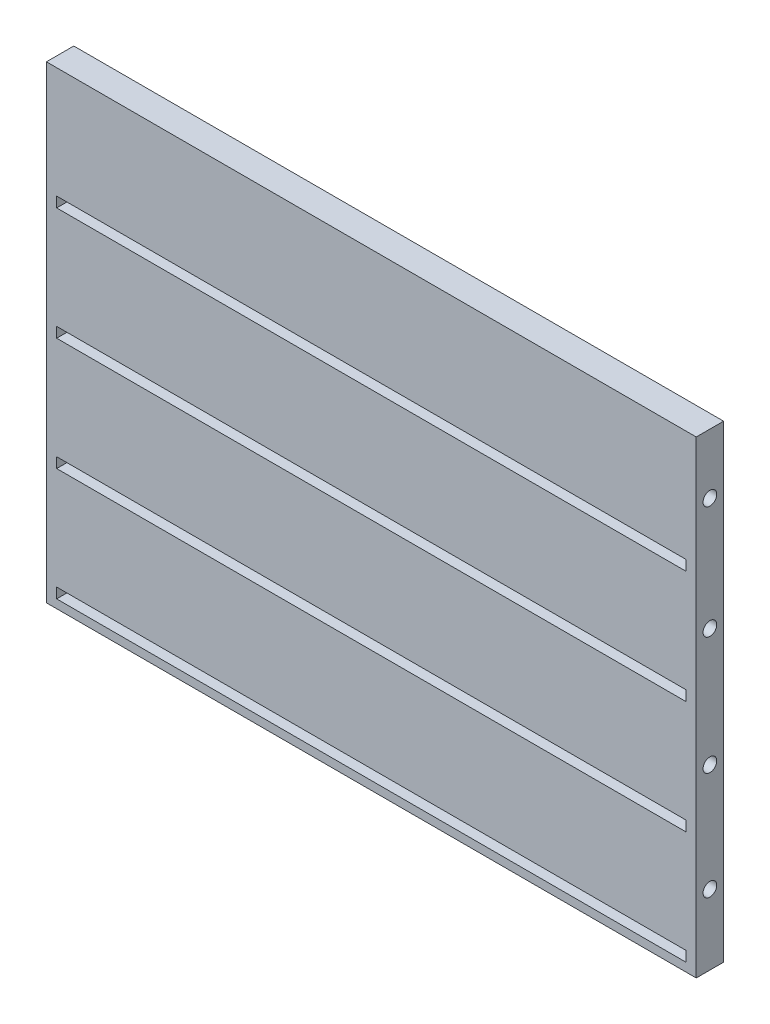
from build123d import *

# Parameters (mm, degrees)
SKETCH1_W           = 76
SKETCH1_H           = 54.8
BOSS_EXTRUDE1_DEPTH = 3.2
CUT_EXTRUDE1_START  = 1.2
SKETCH2_W           = 1.2
SKETCH2_H           = 1.2
CUT_EXTRUDE1_DEPTH  = 73.6
CUT_EXTRUDE2_START  = 76
SKETCH3_R           = 0.8
CUT_EXTRUDE2_DEPTH  = 10


with BuildPart() as part:
    # Sketch1 → Boss-Extrude1 (new body)
    with BuildSketch(Plane.XY):
        with Locations((38, -27.4)):
            Rectangle(SKETCH1_W, SKETCH1_H)
    extrude(amount=BOSS_EXTRUDE1_DEPTH)

    # Sketch2 → Cut-Extrude1 (cut)
    with BuildSketch(Plane(origin=(0, 0, 0), x_dir=(0, 0, -1), z_dir=(1, 0, 0)).offset(CUT_EXTRUDE1_START)):
        with Locations((-2.6, -13.6)):
            Rectangle(SKETCH2_W, SKETCH2_H)
        with Locations((-2.6, -26.8)):
            Rectangle(SKETCH2_W, SKETCH2_H)
        with Locations((-2.6, -40)):
            Rectangle(SKETCH2_W, SKETCH2_H)
        with Locations((-2.6, -53.2)):
            Rectangle(SKETCH2_W, SKETCH2_H)
    extrude(amount=CUT_EXTRUDE1_DEPTH, mode=Mode.SUBTRACT)

    # Sketch3 → Cut-Extrude2 (cut)
    with BuildSketch(Plane(origin=(0, 0, 0), x_dir=(0, 0, -1), z_dir=(1, 0, 0)).offset(CUT_EXTRUDE2_START)):
        with Locations((-1.6, -7)):
            Circle(SKETCH3_R)
        with Locations((-1.6, -20.2)):
            Circle(SKETCH3_R)
        with Locations((-1.6, -33.998867877)):
            Circle(SKETCH3_R)
        with Locations((-1.6, -46.6)):
            Circle(SKETCH3_R)
    extrude(amount=-CUT_EXTRUDE2_DEPTH, mode=Mode.SUBTRACT)


solid = part.part
